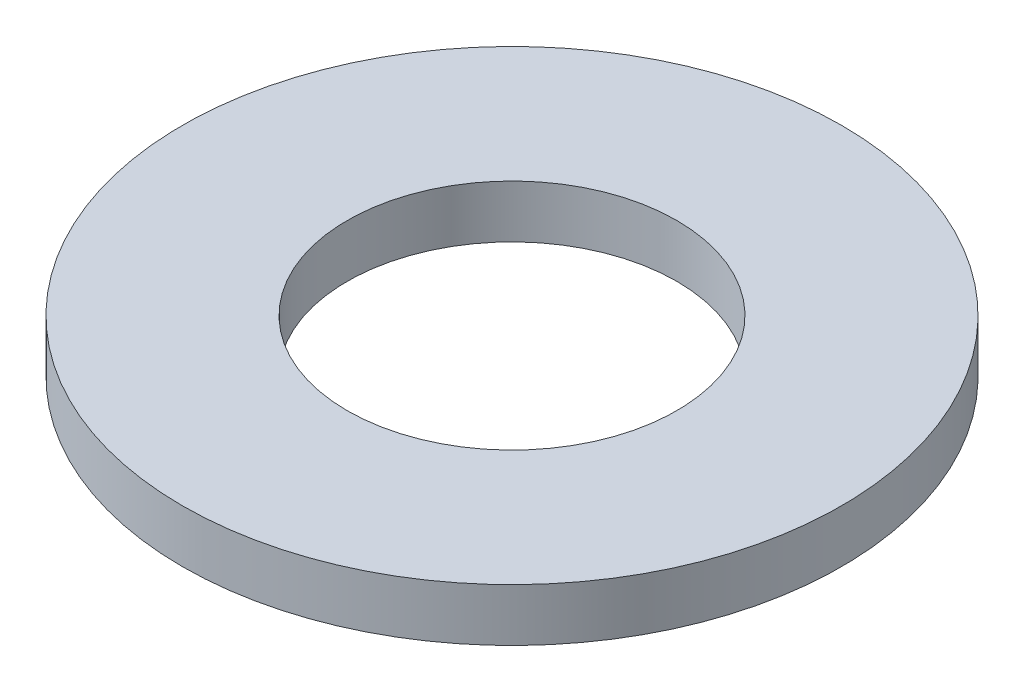
from build123d import *

# Parameters (mm, degrees)
SKETCH1_R           = 5
SKETCH1_R_2         = 2.5
BOSS_EXTRUDE1_DEPTH = 0.8


with BuildPart() as part:
    # Sketch1 → Boss-Extrude1 (new body)
    with BuildSketch(Plane(origin=(0, 0, 0), x_dir=(1, 0, 0), z_dir=(0, 1, 0))):
        Circle(SKETCH1_R)
        Circle(SKETCH1_R_2, mode=Mode.SUBTRACT)
    extrude(amount=BOSS_EXTRUDE1_DEPTH)


solid = part.part
